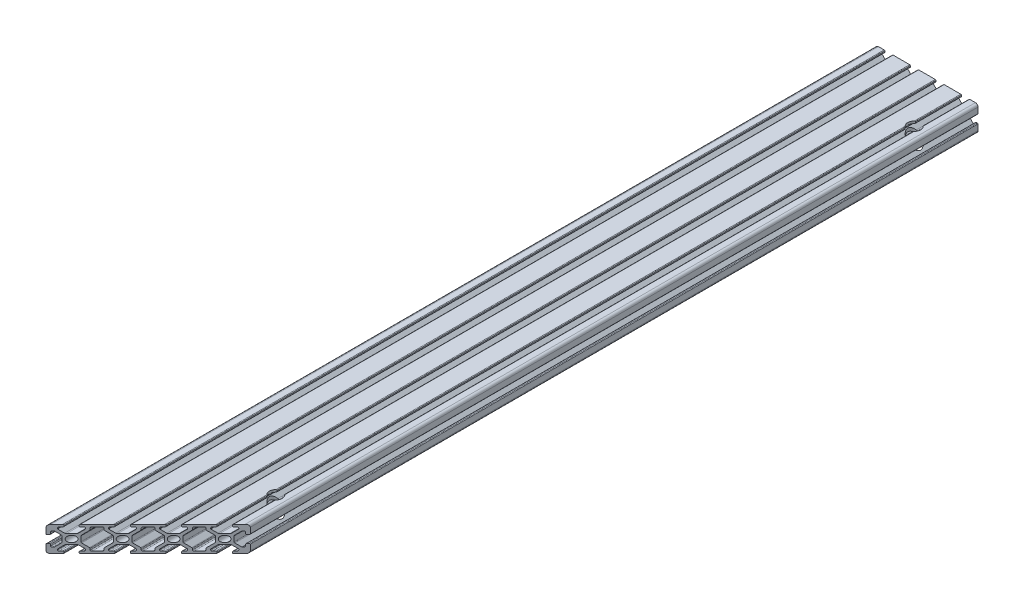
from build123d import *

# Parameters (mm, degrees)
SKETCH1_R               = 2.5
BOSS_EXTRUDE1_DEPTH     = 325
CUT_EXTRUDE1_DEPTH      = 21
SKETCH4_R               = 5
CUT_EXTRUDE3_DEPTH      = 7.35
CUT_EXTRUDE3_DEPTH_BACK = 14.65


with BuildPart() as part:
    # Sketch1 → Boss-Extrude1 (new body, symmetric)
    with BuildSketch(Plane.XY):
        with BuildLine():
            Line((2, 0), (6.5, 0))
            ThreePointArc((6.5, 0), (6.853553391, 0.146446609), (7, 0.5))
            Line((7, 0.5), (7, 1.3))
            ThreePointArc((7, 1.3), (6.853553391, 1.653553391), (6.5, 1.8))
            Line((6.5, 1.8), (5.25, 1.8))
            ThreePointArc((5.25, 1.8), (4.719669914, 2.019669914), (4.5, 2.55))
            Line((4.5, 2.55), (4.5, 3.227207794))
            Line((4.5, 3.227207794), (7.329898987, 6.057106781))
            ThreePointArc((7.329898987, 6.057106781), (7.654322336, 6.273879533), (8.037005769, 6.35))
            Line((8.037005769, 6.35), (11.962994231, 6.35))
            ThreePointArc((11.962994231, 6.35), (12.345677664, 6.273879533), (12.670101013, 6.057106781))
            Line((12.670101013, 6.057106781), (15.5, 3.227207794))
            Line((15.5, 3.227207794), (15.5, 2.55))
            ThreePointArc((15.5, 2.55), (15.280330086, 2.019669914), (14.75, 1.8))
            Line((14.75, 1.8), (13.5, 1.8))
            ThreePointArc((13.5, 1.8), (13.146446609, 1.653553391), (13, 1.3))
            Line((13, 1.3), (13, 0.5))
            ThreePointArc((13, 0.5), (13.146446609, 0.146446609), (13.5, 0))
            Line((13.5, 0), (26.5, 0))
            ThreePointArc((26.5, 0), (26.853553391, 0.146446609), (27, 0.5))
            Line((27, 0.5), (27, 1.3))
            ThreePointArc((27, 1.3), (26.853553391, 1.653553391), (26.5, 1.8))
            Line((26.5, 1.8), (25.25, 1.8))
            ThreePointArc((25.25, 1.8), (24.719669914, 2.019669914), (24.5, 2.55))
            Line((24.5, 2.55), (24.5, 3.227207794))
            Line((24.5, 3.227207794), (27.329898987, 6.057106781))
            ThreePointArc((27.329898987, 6.057106781), (27.654322336, 6.273879533), (28.037005769, 6.35))
            Line((28.037005769, 6.35), (31.962994231, 6.35))
            ThreePointArc((31.962994231, 6.35), (32.345677664, 6.273879533), (32.670101013, 6.057106781))
            Line((32.670101013, 6.057106781), (35.5, 3.227207794))
            Line((35.5, 3.227207794), (35.5, 2.55))
            ThreePointArc((35.5, 2.55), (35.280330086, 2.019669914), (34.75, 1.8))
            Line((34.75, 1.8), (33.5, 1.8))
            ThreePointArc((33.5, 1.8), (33.146446609, 1.653553391), (33, 1.3))
            Line((33, 1.3), (33, 0.5))
            ThreePointArc((33, 0.5), (33.146446609, 0.146446609), (33.5, 0))
            Line((33.5, 0), (46.5, 0))
            ThreePointArc((46.5, 0), (46.853553391, 0.146446609), (47, 0.5))
            Line((47, 0.5), (47, 1.3))
            ThreePointArc((47, 1.3), (46.853553391, 1.653553391), (46.5, 1.8))
            Line((46.5, 1.8), (45.25, 1.8))
            ThreePointArc((45.25, 1.8), (44.719669914, 2.019669914), (44.5, 2.55))
            Line((44.5, 2.55), (44.5, 3.227207794))
            Line((44.5, 3.227207794), (47.329898987, 6.057106781))
            ThreePointArc((47.329898987, 6.057106781), (47.654322336, 6.273879533), (48.037005769, 6.35))
            Line((48.037005769, 6.35), (51.962994231, 6.35))
            ThreePointArc((51.962994231, 6.35), (52.345677664, 6.273879533), (52.670101013, 6.057106781))
            Line((52.670101013, 6.057106781), (55.5, 3.227207794))
            Line((55.5, 3.227207794), (55.5, 2.55))
            ThreePointArc((55.5, 2.55), (55.280330086, 2.019669914), (54.75, 1.8))
            Line((54.75, 1.8), (53.5, 1.8))
            ThreePointArc((53.5, 1.8), (53.146446609, 1.653553391), (53, 1.3))
            Line((53, 1.3), (53, 0.5))
            ThreePointArc((53, 0.5), (53.146446609, 0.146446609), (53.5, 0))
            Line((53.5, 0), (66.5, 0))
            ThreePointArc((66.5, 0), (66.853553391, 0.146446609), (67, 0.5))
            Line((67, 0.5), (67, 1.3))
            ThreePointArc((67, 1.3), (66.853553391, 1.653553391), (66.5, 1.8))
            Line((66.5, 1.8), (65.25, 1.8))
            ThreePointArc((65.25, 1.8), (64.719669914, 2.019669914), (64.5, 2.55))
            Line((64.5, 2.55), (64.5, 3.227207794))
            Line((64.5, 3.227207794), (67.329898987, 6.057106781))
            ThreePointArc((67.329898987, 6.057106781), (67.654322336, 6.273879533), (68.037005769, 6.35))
            Line((68.037005769, 6.35), (71.962994231, 6.35))
            ThreePointArc((71.962994231, 6.35), (72.345677664, 6.273879533), (72.670101013, 6.057106781))
            Line((72.670101013, 6.057106781), (75.5, 3.227207794))
            Line((75.5, 3.227207794), (75.5, 2.55))
            ThreePointArc((75.5, 2.55), (75.280330086, 2.019669914), (74.75, 1.8))
            Line((74.75, 1.8), (73.5, 1.8))
            ThreePointArc((73.5, 1.8), (73.146446609, 1.653553391), (73, 1.3))
            Line((73, 1.3), (73, 0.5))
            ThreePointArc((73, 0.5), (73.146446609, 0.146446609), (73.5, 0))
            Line((73.5, 0), (78, 0))
            ThreePointArc((78, 0), (79.414213562, 0.585786438), (80, 2))
            Line((80, 2), (80, 6.5))
            ThreePointArc((80, 6.5), (79.853553391, 6.853553391), (79.5, 7))
            Line((79.5, 7), (78.7, 7))
            ThreePointArc((78.7, 7), (78.346446609, 6.853553391), (78.2, 6.5))
            Line((78.2, 6.5), (78.2, 5.25))
            ThreePointArc((78.2, 5.25), (77.980330086, 4.719669914), (77.45, 4.5))
            Line((77.45, 4.5), (76.772792206, 4.5))
            Line((76.772792206, 4.5), (73.942893219, 7.329898987))
            ThreePointArc((73.942893219, 7.329898987), (73.726120467, 7.654322336), (73.65, 8.037005769))
            Line((73.65, 8.037005769), (73.65, 11.962994231))
            ThreePointArc((73.65, 11.962994231), (73.726120467, 12.345677664), (73.942893219, 12.670101013))
            Line((73.942893219, 12.670101013), (76.772792206, 15.5))
            Line((76.772792206, 15.5), (77.45, 15.5))
            ThreePointArc((77.45, 15.5), (77.980330086, 15.280330086), (78.2, 14.75))
            Line((78.2, 14.75), (78.2, 13.5))
            ThreePointArc((78.2, 13.5), (78.346446609, 13.146446609), (78.7, 13))
            Line((78.7, 13), (79.5, 13))
            ThreePointArc((79.5, 13), (79.853553391, 13.146446609), (80, 13.5))
            Line((80, 13.5), (80, 18))
            ThreePointArc((80, 18), (79.414213562, 19.414213562), (78, 20))
            Line((78, 20), (73.5, 20))
            ThreePointArc((73.5, 20), (73.146446609, 19.853553391), (73, 19.5))
            Line((73, 19.5), (73, 18.7))
            ThreePointArc((73, 18.7), (73.146446609, 18.346446609), (73.5, 18.2))
            Line((73.5, 18.2), (74.75, 18.2))
            ThreePointArc((74.75, 18.2), (75.280330086, 17.980330086), (75.5, 17.45))
            Line((75.5, 17.45), (75.5, 16.772792206))
            Line((75.5, 16.772792206), (72.670101013, 13.942893219))
            ThreePointArc((72.670101013, 13.942893219), (72.345677664, 13.726120467), (71.962994231, 13.65))
            Line((71.962994231, 13.65), (68.037005769, 13.65))
            ThreePointArc((68.037005769, 13.65), (67.654322336, 13.726120467), (67.329898987, 13.942893219))
            Line((67.329898987, 13.942893219), (64.5, 16.772792206))
            Line((64.5, 16.772792206), (64.5, 17.45))
            ThreePointArc((64.5, 17.45), (64.719669914, 17.980330086), (65.25, 18.2))
            Line((65.25, 18.2), (66.5, 18.2))
            ThreePointArc((66.5, 18.2), (66.853553391, 18.346446609), (67, 18.7))
            Line((67, 18.7), (67, 19.5))
            ThreePointArc((67, 19.5), (66.853553391, 19.853553391), (66.5, 20))
            Line((66.5, 20), (53.5, 20))
            ThreePointArc((53.5, 20), (53.146446609, 19.853553391), (53, 19.5))
            Line((53, 19.5), (53, 18.7))
            ThreePointArc((53, 18.7), (53.146446609, 18.346446609), (53.5, 18.2))
            Line((53.5, 18.2), (54.75, 18.2))
            ThreePointArc((54.75, 18.2), (55.280330086, 17.980330086), (55.5, 17.45))
            Line((55.5, 17.45), (55.5, 16.772792206))
            Line((55.5, 16.772792206), (52.670101013, 13.942893219))
            ThreePointArc((52.670101013, 13.942893219), (52.345677664, 13.726120467), (51.962994231, 13.65))
            Line((51.962994231, 13.65), (48.037005769, 13.65))
            ThreePointArc((48.037005769, 13.65), (47.654322336, 13.726120467), (47.329898987, 13.942893219))
            Line((47.329898987, 13.942893219), (44.5, 16.772792206))
            Line((44.5, 16.772792206), (44.5, 17.45))
            ThreePointArc((44.5, 17.45), (44.719669914, 17.980330086), (45.25, 18.2))
            Line((45.25, 18.2), (46.5, 18.2))
            ThreePointArc((46.5, 18.2), (46.853553391, 18.346446609), (47, 18.7))
            Line((47, 18.7), (47, 19.5))
            ThreePointArc((47, 19.5), (46.853553391, 19.853553391), (46.5, 20))
            Line((46.5, 20), (33.5, 20))
            ThreePointArc((33.5, 20), (33.146446609, 19.853553391), (33, 19.5))
            Line((33, 19.5), (33, 18.7))
            ThreePointArc((33, 18.7), (33.146446609, 18.346446609), (33.5, 18.2))
            Line((33.5, 18.2), (34.75, 18.2))
            ThreePointArc((34.75, 18.2), (35.280330086, 17.980330086), (35.5, 17.45))
            Line((35.5, 17.45), (35.5, 16.772792206))
            Line((35.5, 16.772792206), (32.670101013, 13.942893219))
            ThreePointArc((32.670101013, 13.942893219), (32.345677664, 13.726120467), (31.962994231, 13.65))
            Line((31.962994231, 13.65), (28.037005769, 13.65))
            ThreePointArc((28.037005769, 13.65), (27.654322336, 13.726120467), (27.329898987, 13.942893219))
            Line((27.329898987, 13.942893219), (24.5, 16.772792206))
            Line((24.5, 16.772792206), (24.5, 17.45))
            ThreePointArc((24.5, 17.45), (24.719669914, 17.980330086), (25.25, 18.2))
            Line((25.25, 18.2), (26.5, 18.2))
            ThreePointArc((26.5, 18.2), (26.853553391, 18.346446609), (27, 18.7))
            Line((27, 18.7), (27, 19.5))
            ThreePointArc((27, 19.5), (26.853553391, 19.853553391), (26.5, 20))
            Line((26.5, 20), (13.5, 20))
            ThreePointArc((13.5, 20), (13.146446609, 19.853553391), (13, 19.5))
            Line((13, 19.5), (13, 18.7))
            ThreePointArc((13, 18.7), (13.146446609, 18.346446609), (13.5, 18.2))
            Line((13.5, 18.2), (14.75, 18.2))
            ThreePointArc((14.75, 18.2), (15.280330086, 17.980330086), (15.5, 17.45))
            Line((15.5, 17.45), (15.5, 16.772792206))
            Line((15.5, 16.772792206), (12.670101013, 13.942893219))
            ThreePointArc((12.670101013, 13.942893219), (12.345677664, 13.726120467), (11.962994231, 13.65))
            Line((11.962994231, 13.65), (8.037005769, 13.65))
            ThreePointArc((8.037005769, 13.65), (7.654322336, 13.726120467), (7.329898987, 13.942893219))
            Line((7.329898987, 13.942893219), (4.5, 16.772792206))
            Line((4.5, 16.772792206), (4.5, 17.45))
            ThreePointArc((4.5, 17.45), (4.719669914, 17.980330086), (5.25, 18.2))
            Line((5.25, 18.2), (6.5, 18.2))
            ThreePointArc((6.5, 18.2), (6.853553391, 18.346446609), (7, 18.7))
            Line((7, 18.7), (7, 19.5))
            ThreePointArc((7, 19.5), (6.853553391, 19.853553391), (6.5, 20))
            Line((6.5, 20), (2, 20))
            ThreePointArc((2, 20), (0.585786438, 19.414213562), (0, 18))
            Line((0, 18), (0, 13.5))
            ThreePointArc((0, 13.5), (0.146446609, 13.146446609), (0.5, 13))
            Line((0.5, 13), (1.3, 13))
            ThreePointArc((1.3, 13), (1.653553391, 13.146446609), (1.8, 13.5))
            Line((1.8, 13.5), (1.8, 14.75))
            ThreePointArc((1.8, 14.75), (2.019669914, 15.280330086), (2.55, 15.5))
            Line((2.55, 15.5), (3.227207794, 15.5))
            Line((3.227207794, 15.5), (6.057106781, 12.670101013))
            ThreePointArc((6.057106781, 12.670101013), (6.273879533, 12.345677664), (6.35, 11.962994231))
            Line((6.35, 11.962994231), (6.35, 8.037005769))
            ThreePointArc((6.35, 8.037005769), (6.273879533, 7.654322336), (6.057106781, 7.329898987))
            Line((6.057106781, 7.329898987), (3.227207794, 4.5))
            Line((3.227207794, 4.5), (2.55, 4.5))
            ThreePointArc((2.55, 4.5), (2.019669914, 4.719669914), (1.8, 5.25))
            Line((1.8, 5.25), (1.8, 6.5))
            ThreePointArc((1.8, 6.5), (1.653553391, 6.853553391), (1.3, 7))
            Line((1.3, 7), (0.5, 7))
            ThreePointArc((0.5, 7), (0.146446609, 6.853553391), (0, 6.5))
            Line((0, 6.5), (0, 2))
            ThreePointArc((0, 2), (0.585786438, 0.585786438), (2, 0))
        make_face()
        with Locations((10, 10)):
            Circle(SKETCH1_R, mode=Mode.SUBTRACT)
        with Locations((30, 10)):
            Circle(SKETCH1_R, mode=Mode.SUBTRACT)
        with Locations((50, 10)):
            Circle(SKETCH1_R, mode=Mode.SUBTRACT)
        with Locations((70, 10)):
            Circle(SKETCH1_R, mode=Mode.SUBTRACT)
        with BuildLine():
            Line((33.942893219, 12.670101013), (37.080330086, 15.80753788))
            ThreePointArc((37.080330086, 15.80753788), (37.242909649, 16.050855391), (37.3, 16.337867966))
            Line((37.3, 16.337867966), (37.3, 17.45))
            ThreePointArc((37.3, 17.45), (37.519669914, 17.980330086), (38.05, 18.2))
            Line((38.05, 18.2), (41.95, 18.2))
            ThreePointArc((41.95, 18.2), (42.480330086, 17.980330086), (42.7, 17.45))
            Line((42.7, 17.45), (42.7, 16.337867966))
            ThreePointArc((42.7, 16.337867966), (42.757090351, 16.050855391), (42.919669914, 15.80753788))
            Line((42.919669914, 15.80753788), (46.057106781, 12.670101013))
            ThreePointArc((46.057106781, 12.670101013), (46.273879533, 12.345677664), (46.35, 11.962994231))
            Line((46.35, 11.962994231), (46.35, 8.037005769))
            ThreePointArc((46.35, 8.037005769), (46.273879533, 7.654322336), (46.057106781, 7.329898987))
            Line((46.057106781, 7.329898987), (42.919669914, 4.19246212))
            ThreePointArc((42.919669914, 4.19246212), (42.757090351, 3.949144609), (42.7, 3.662132034))
            Line((42.7, 3.662132034), (42.7, 2.55))
            ThreePointArc((42.7, 2.55), (42.480330086, 2.019669914), (41.95, 1.8))
            Line((41.95, 1.8), (38.05, 1.8))
            ThreePointArc((38.05, 1.8), (37.519669914, 2.019669914), (37.3, 2.55))
            Line((37.3, 2.55), (37.3, 3.662132034))
            ThreePointArc((37.3, 3.662132034), (37.242909649, 3.949144609), (37.080330086, 4.19246212))
            Line((37.080330086, 4.19246212), (33.942893219, 7.329898987))
            ThreePointArc((33.942893219, 7.329898987), (33.726120467, 7.654322336), (33.65, 8.037005769))
            Line((33.65, 8.037005769), (33.65, 11.962994231))
            ThreePointArc((33.65, 11.962994231), (33.726120467, 12.345677664), (33.942893219, 12.670101013))
        make_face(mode=Mode.SUBTRACT)
        with BuildLine():
            Line((22.919669914, 15.80753788), (26.057106781, 12.670101013))
            ThreePointArc((26.057106781, 12.670101013), (26.273879533, 12.345677664), (26.35, 11.962994231))
            Line((26.35, 11.962994231), (26.35, 8.037005769))
            ThreePointArc((26.35, 8.037005769), (26.273879533, 7.654322336), (26.057106781, 7.329898987))
            Line((26.057106781, 7.329898987), (22.919669914, 4.19246212))
            ThreePointArc((22.919669914, 4.19246212), (22.757090351, 3.949144609), (22.7, 3.662132034))
            Line((22.7, 3.662132034), (22.7, 2.55))
            ThreePointArc((22.7, 2.55), (22.480330086, 2.019669914), (21.95, 1.8))
            Line((21.95, 1.8), (18.05, 1.8))
            ThreePointArc((18.05, 1.8), (17.519669914, 2.019669914), (17.3, 2.55))
            Line((17.3, 2.55), (17.3, 3.662132034))
            ThreePointArc((17.3, 3.662132034), (17.242909649, 3.949144609), (17.080330086, 4.19246212))
            Line((17.080330086, 4.19246212), (13.942893219, 7.329898987))
            ThreePointArc((13.942893219, 7.329898987), (13.726120467, 7.654322336), (13.65, 8.037005769))
            Line((13.65, 8.037005769), (13.65, 11.962994231))
            ThreePointArc((13.65, 11.962994231), (13.726120467, 12.345677664), (13.942893219, 12.670101013))
            Line((13.942893219, 12.670101013), (17.080330086, 15.80753788))
            ThreePointArc((17.080330086, 15.80753788), (17.242909649, 16.050855391), (17.3, 16.337867966))
            Line((17.3, 16.337867966), (17.3, 17.45))
            ThreePointArc((17.3, 17.45), (17.519669914, 17.980330086), (18.05, 18.2))
            Line((18.05, 18.2), (21.95, 18.2))
            ThreePointArc((21.95, 18.2), (22.480330086, 17.980330086), (22.7, 17.45))
            Line((22.7, 17.45), (22.7, 16.337867966))
            ThreePointArc((22.7, 16.337867966), (22.757090351, 16.050855391), (22.919669914, 15.80753788))
        make_face(mode=Mode.SUBTRACT)
        with BuildLine():
            Line((62.919669914, 15.80753788), (66.057106781, 12.670101013))
            ThreePointArc((66.057106781, 12.670101013), (66.273879533, 12.345677664), (66.35, 11.962994231))
            Line((66.35, 11.962994231), (66.35, 8.037005769))
            ThreePointArc((66.35, 8.037005769), (66.273879533, 7.654322336), (66.057106781, 7.329898987))
            Line((66.057106781, 7.329898987), (62.919669914, 4.19246212))
            ThreePointArc((62.919669914, 4.19246212), (62.757090351, 3.949144609), (62.7, 3.662132034))
            Line((62.7, 3.662132034), (62.7, 2.55))
            ThreePointArc((62.7, 2.55), (62.480330086, 2.019669914), (61.95, 1.8))
            Line((61.95, 1.8), (58.05, 1.8))
            ThreePointArc((58.05, 1.8), (57.519669914, 2.019669914), (57.3, 2.55))
            Line((57.3, 2.55), (57.3, 3.662132034))
            ThreePointArc((57.3, 3.662132034), (57.242909649, 3.949144609), (57.080330086, 4.19246212))
            Line((57.080330086, 4.19246212), (53.942893219, 7.329898987))
            ThreePointArc((53.942893219, 7.329898987), (53.726120467, 7.654322336), (53.65, 8.037005769))
            Line((53.65, 8.037005769), (53.65, 11.962994231))
            ThreePointArc((53.65, 11.962994231), (53.726120467, 12.345677664), (53.942893219, 12.670101013))
            Line((53.942893219, 12.670101013), (57.080330086, 15.80753788))
            ThreePointArc((57.080330086, 15.80753788), (57.242909649, 16.050855391), (57.3, 16.337867966))
            Line((57.3, 16.337867966), (57.3, 17.45))
            ThreePointArc((57.3, 17.45), (57.519669914, 17.980330086), (58.05, 18.2))
            Line((58.05, 18.2), (61.95, 18.2))
            ThreePointArc((61.95, 18.2), (62.480330086, 17.980330086), (62.7, 17.45))
            Line((62.7, 17.45), (62.7, 16.337867966))
            ThreePointArc((62.7, 16.337867966), (62.757090351, 16.050855391), (62.919669914, 15.80753788))
        make_face(mode=Mode.SUBTRACT)
    extrude(amount=BOSS_EXTRUDE1_DEPTH, both=True)

    # Sketch2 → Cut-Extrude1 (cut, through all)
    with BuildSketch(Plane(origin=(0, 20, 0), x_dir=(1, 0, 0), z_dir=(0, 1, 0))):
        Polygon((0, -325), (80, -245), (80, -325), align=None)
    extrude(amount=-CUT_EXTRUDE1_DEPTH, mode=Mode.SUBTRACT)

    # Sketch4 → Cut-Extrude3 (cut, two sides)
    with BuildSketch(Plane(origin=(0, 6.35, 0), x_dir=(-1, 0, 0), z_dir=(0, -1, 0))) as cut_extrude3_sk:
        with Locations((-70, 285)):
            Circle(SKETCH4_R)
        with Locations((-70, -215)):
            Circle(SKETCH4_R)
    extrude(amount=CUT_EXTRUDE3_DEPTH, mode=Mode.SUBTRACT)
    extrude(cut_extrude3_sk.sketch, amount=-CUT_EXTRUDE3_DEPTH_BACK, mode=Mode.SUBTRACT)


solid = part.part
